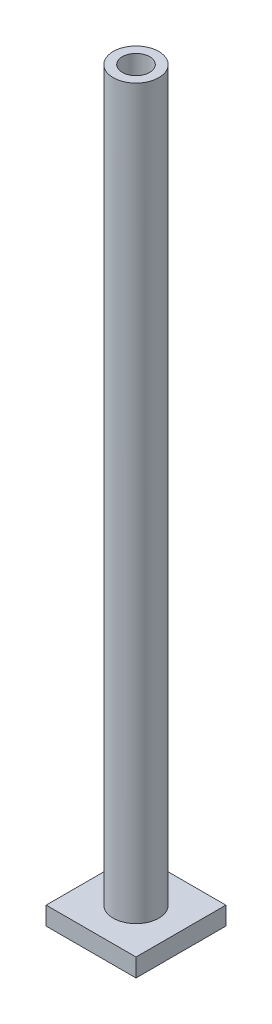
from build123d import *

# Parameters (mm, degrees)
SKETCH1_W             = 15.8
SKETCH1_H             = 15.8
BASE_DEPTH            = 3.2
BOTTOM_CUT_DEPTH      = 2
SKETCH3_R             = 4
SKETCH3_R_2           = 2.4
LAMP_POST_DEPTH       = 128
WIRE_BOTTOM_CUT_REACH = 5.2
SKETCH4_R             = 2.4


with BuildPart() as part:
    # Sketch1 → Base (new body)
    with BuildSketch(Plane(origin=(0, 0, 0), x_dir=(1, 0, 0), z_dir=(0, 1, 0))):
        Rectangle(SKETCH1_W, SKETCH1_H)
    extrude(amount=BASE_DEPTH)

    # Sketch2 → Bottom cut (cut)
    with BuildSketch(Plane.XZ):
        with BuildLine():
            Line((6.6, -6.6), (6.6, 6.6))
            Line((6.6, 6.6), (-6.6, 6.6))
            Line((-6.6, 6.6), (-6.6, -6.6))
            Line((-6.6, -6.6), (-1.25, -6.6))
            Line((-1.25, -6.6), (-1.25, -3.161882351))
            ThreePointArc((-1.25, -3.161882351), (-1.911805429, 2.811583184), (3.4, 0))
            ThreePointArc((3.4, 0), (2.811583184, -1.911805429), (1.25, -3.161882351))
            Line((1.25, -3.161882351), (1.25, -6.6))
            Line((1.25, -6.6), (6.6, -6.6))
        make_face()
        with BuildLine():
            ThreePointArc((-1.25, -2.165063509), (0, -2.5), (1.25, -2.165063509))
            Line((1.25, -2.165063509), (-1.25, -2.165063509))
        make_face()
        with BuildLine():
            Line((-1.25, -2.165063509), (1.25, -2.165063509))
            ThreePointArc((1.25, -2.165063509), (2.165063509, -1.25), (2.5, 0))
            ThreePointArc((2.5, 0), (-1.25, 2.165063509), (-1.25, -2.165063509))
        make_face()
        with BuildLine():
            Line((-1.25, -6.6), (1.25, -6.6))
            Line((1.25, -6.6), (1.25, -3.161882351))
            ThreePointArc((1.25, -3.161882351), (0, -3.4), (-1.25, -3.161882351))
            Line((-1.25, -3.161882351), (-1.25, -6.6))
        make_face()
    extrude(amount=-BOTTOM_CUT_DEPTH, mode=Mode.SUBTRACT)

    # Sketch3 → Lamp post (add)
    with BuildSketch(Plane(origin=(0, 3.2, 0), x_dir=(1, 0, 0), z_dir=(0, 1, 0))):
        Circle(SKETCH3_R)
        Circle(SKETCH3_R_2, mode=Mode.SUBTRACT)
    extrude(amount=LAMP_POST_DEPTH)

    # Sketch4 → Wire bottom cut (cut, up to next)
    with BuildSketch(Plane(origin=(0, 3.2, 0), x_dir=(1, 0, 0), z_dir=(0, 1, 0)), mode=Mode.PRIVATE) as wire_bottom_cut_sk1:
        Circle(SKETCH4_R)
    wire_bottom_cut_tool1 = extrude(wire_bottom_cut_sk1.sketch, amount=-WIRE_BOTTOM_CUT_REACH, mode=Mode.PRIVATE) & part.part
    add(wire_bottom_cut_tool1.solids().sort_by_distance((0, 3.2, 0))[0], mode=Mode.SUBTRACT)


solid = part.part
